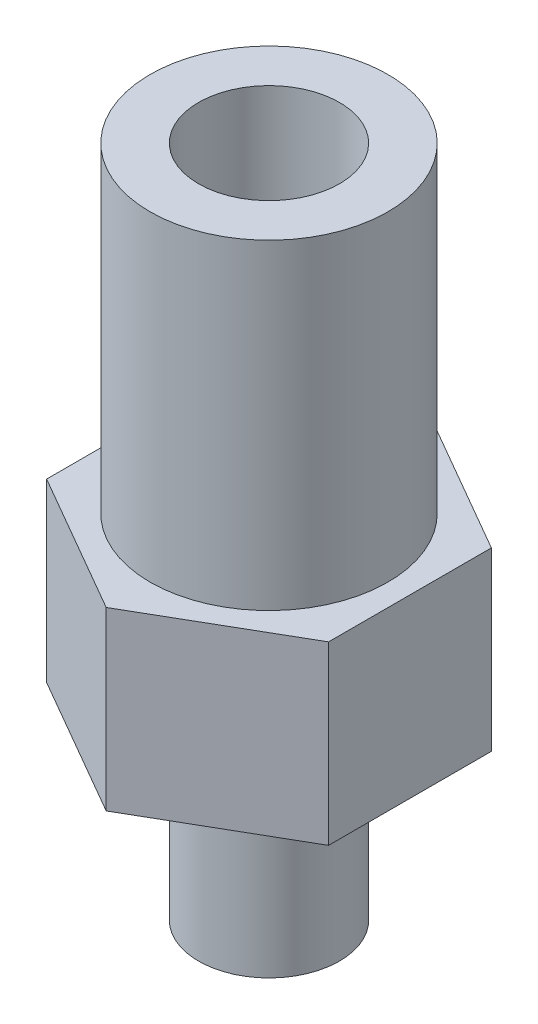
from build123d import *

# Parameters (mm, degrees)
BOSS_EXTRUDE1_DEPTH = 10
SKETCH2_R           = 6.75
BOSS_EXTRUDE2_DEPTH = 18.2
SKETCH3_R           = 4
BOSS_EXTRUDE3_DEPTH = 10
SKETCH4_R           = 4
CUT_EXTRUDE1_DEPTH  = 26.4


with BuildPart() as part:
    # Sketch1 → Boss-Extrude1 (new body)
    with BuildSketch(Plane(origin=(0, 0, 0), x_dir=(1, 0, 0), z_dir=(0, 1, 0))):
        Polygon((0, 9.237604307), (-8, 4.618802154), (-8, -4.618802154), (0, -9.237604307), (8, -4.618802154), (8, 4.618802154), align=None)
    extrude(amount=BOSS_EXTRUDE1_DEPTH)

    # Sketch2 → Boss-Extrude2 (add)
    with BuildSketch(Plane(origin=(0, 10, 0), x_dir=(1, 0, 0), z_dir=(0, 1, 0))):
        Circle(SKETCH2_R)
    extrude(amount=BOSS_EXTRUDE2_DEPTH)

    # Sketch3 → Boss-Extrude3 (add)
    with BuildSketch(Plane.XZ):
        Circle(SKETCH3_R)
    extrude(amount=BOSS_EXTRUDE3_DEPTH)

    # Sketch4 → Cut-Extrude1 (cut)
    with BuildSketch(Plane(origin=(0, 28.2, 0), x_dir=(1, 0, 0), z_dir=(0, 1, 0))):
        Circle(SKETCH4_R)
    extrude(amount=-CUT_EXTRUDE1_DEPTH, mode=Mode.SUBTRACT)


solid = part.part
